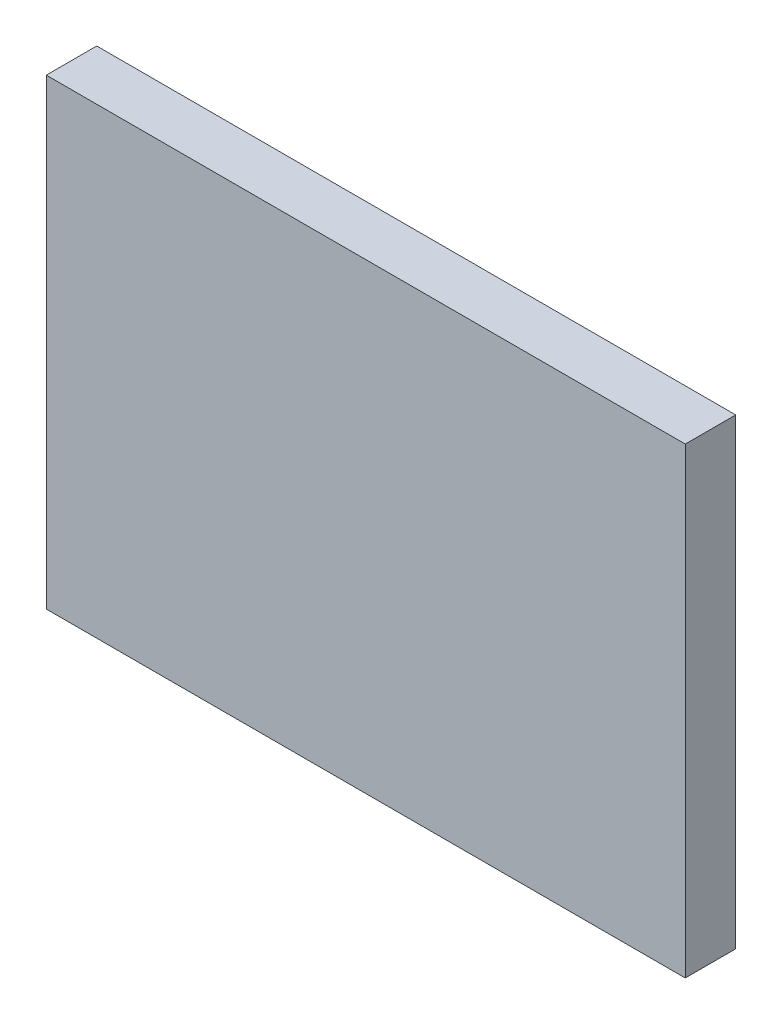
from build123d import *

# Parameters (mm, degrees)
SKETCH1_W           = 38
SKETCH1_H           = 27.5
BOSS_EXTRUDE1_DEPTH = 3


with BuildPart() as part:
    # Sketch1 → Boss-Extrude1 (new body)
    with BuildSketch(Plane.XY):
        with Locations((0, -63.271844655)):
            Rectangle(SKETCH1_W, SKETCH1_H)
    extrude(amount=BOSS_EXTRUDE1_DEPTH)


solid = part.part
